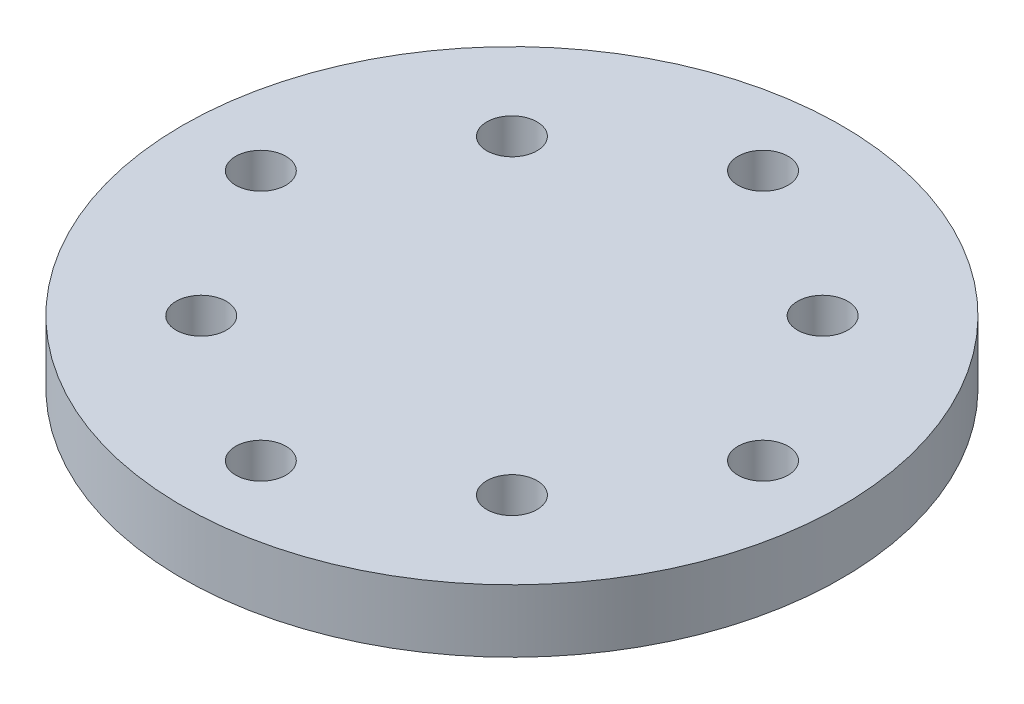
from build123d import *

# Parameters (mm, degrees)
M2_TAPPED_HOLE1_AT_2_COUNT = 2
M2_TAPPED_HOLE1_AT_2_PITCH = 5.814124225
CIRPATTERN1_COUNT          = 4


with BuildPart() as part:
    # Sketch1 → Revolve1 (revolve)
    with BuildSketch(Plane.XY):
        Polygon((-5, 0), (-5, 3), (-10.5, 3), (-10.5, 5), (0, 5), (0, 0), align=None)
    revolve(axis=Axis((0, 5, 0), (0, -1, 0)))

    # Sketch4 → M2 Tapped Hole1 (revolve, cut)
    with BuildSketch(Plane(origin=(8, 5, 0), x_dir=(0, 0, 1), z_dir=(1, 0, 0))):
        Polygon((0, 0), (0, 6.480688495), (0.8, 6), (0.8, 0), align=None)
    m2_tapped_hole1 = revolve(axis=Axis((8, 11.35, 0), (0, -1, 0)), mode=Mode.SUBTRACT)

    # M2 Tapped Hole1 at 2: M2 Tapped Hole1 ×2
    with Locations(*[Vector(-0.524628029, 0, 0.851331564) * (i * M2_TAPPED_HOLE1_AT_2_PITCH) for i in range(1, M2_TAPPED_HOLE1_AT_2_COUNT)]):
        add(m2_tapped_hole1, mode=Mode.SUBTRACT)

    # CirPattern1: M2 Tapped Hole1 ×4 about axis
    cirpattern1_axis = Axis((0, 0, 0), (0, 1, 0))
    for i in range(1, CIRPATTERN1_COUNT):
        add(m2_tapped_hole1.rotate(cirpattern1_axis, i * 360 / CIRPATTERN1_COUNT), mode=Mode.SUBTRACT)

    # CirPattern1 copy 1 sketch → CirPattern1 copy 1 (revolve, cut)
    with BuildSketch(Plane(origin=(4.949747468, 5, -4.949747468), x_dir=(1, 0, 0), z_dir=(0, 0, -1))):
        Polygon((0, 0), (0, 6.480688495), (0.8, 6), (0.8, 0), align=None)
    revolve(axis=Axis((4.949747468, 11.35, -4.949747468), (0, -1, 0)), mode=Mode.SUBTRACT)

    # CirPattern1 copy 2 sketch → CirPattern1 copy 2 (revolve, cut)
    with BuildSketch(Plane(origin=(-4.949747468, 5, -4.949747468), x_dir=(0, 0, -1), z_dir=(-1, 0, 0))):
        Polygon((0, 0), (0, 6.480688495), (0.8, 6), (0.8, 0), align=None)
    revolve(axis=Axis((-4.949747468, 11.35, -4.949747468), (0, -1, 0)), mode=Mode.SUBTRACT)

    # CirPattern1 copy 3 sketch → CirPattern1 copy 3 (revolve, cut)
    with BuildSketch(Plane(origin=(-4.949747468, 5, 4.949747468), x_dir=(-1, 0, 0), z_dir=(0, 0, 1))):
        Polygon((0, 0), (0, 6.480688495), (0.8, 6), (0.8, 0), align=None)
    revolve(axis=Axis((-4.949747468, 11.35, 4.949747468), (0, -1, 0)), mode=Mode.SUBTRACT)


solid = part.part
